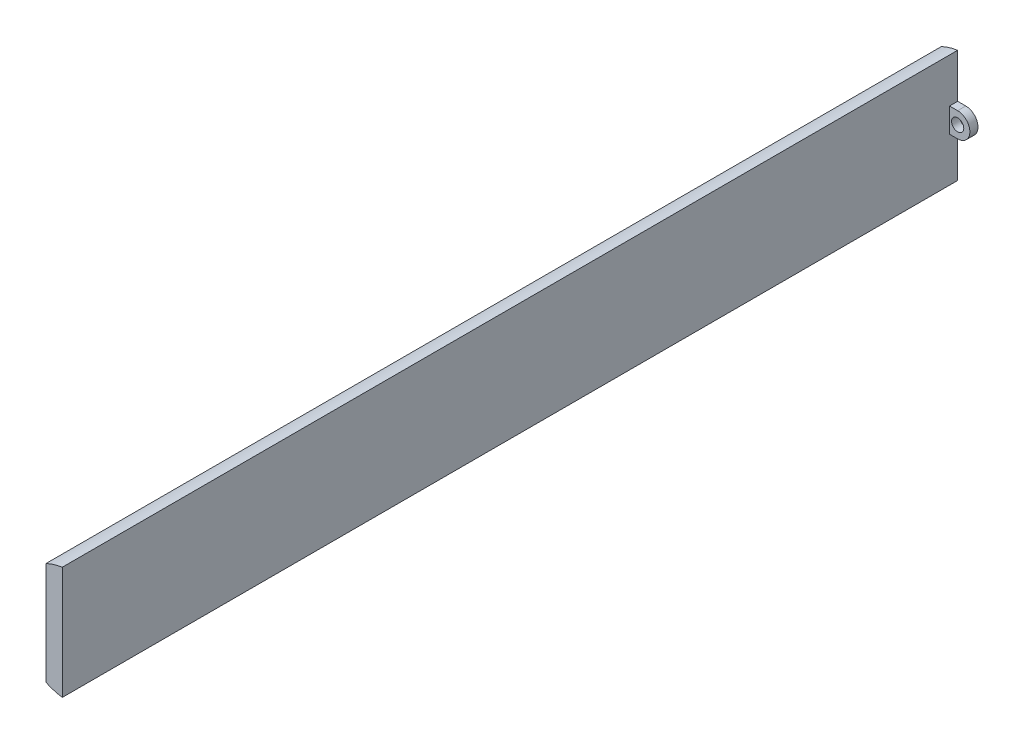
from build123d import *

# Parameters (mm, degrees)
EXTRUDE_1_DEPTH = 110
SKETCH_1_4_R    = 0.75
EXTRUDE_2_DEPTH = 1


with BuildPart() as part:
    # Sketch 1 → Extrude 1 (new body)
    with BuildSketch(Plane.XY):
        with BuildLine():
            Line((-1, 6.92820323), (-1, 1.5))
            Line((-1, 1.5), (-1, -1.5))
            Line((-1, -1.5), (-1, -6.92820323))
            ThreePointArc((-1, -6.92820323), (-2.022646212, -6.701410471), (-3, -6.32455532))
            Line((-3, -6.32455532), (-3, 6.32455532))
            ThreePointArc((-3, 6.32455532), (-2.022646212, 6.701410471), (-1, 6.92820323))
        make_face()
    extrude(amount=EXTRUDE_1_DEPTH)

    # Sketch 1_4 → Extrude 2 (add)
    with BuildSketch(Plane.XY):
        with BuildLine():
            Line((0, -1.5), (-1, -1.5))
            Line((-1, -1.5), (-1, 1.5))
            Line((-1, 1.5), (0, 1.5))
            ThreePointArc((0, 1.5), (1.5, 0), (0, -1.5))
        make_face()
        Circle(SKETCH_1_4_R, mode=Mode.SUBTRACT)
    extrude(amount=EXTRUDE_2_DEPTH)


solid = part.part
